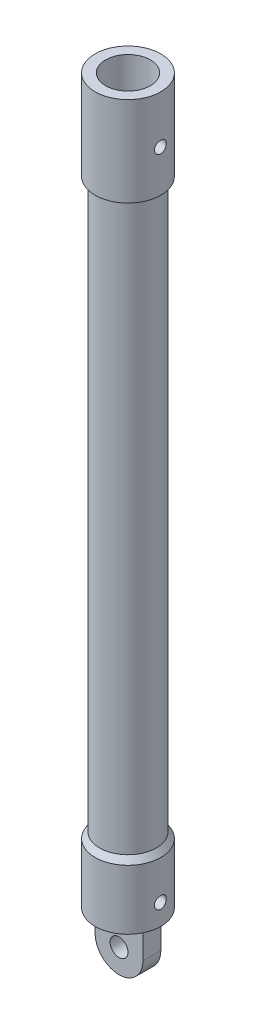
from build123d import *

# Parameters (mm, degrees)
BOSS_EXTRUDE1_DEPTH      = 1.5
BOSS_EXTRUDE1_DEPTH_BACK = 1.5
SKETCH2_R                = 1.5
SKETCH3_R                = 1
CUT_EXTRUDE1_DEPTH       = 10


with BuildPart() as part:
    # Sketch1 → Revolve1 (revolve)
    with BuildSketch(Plane.XY):
        Polygon((0, 0), (-5.5, 0), (-5.5, 10), (-4.75, 11), (-4.75, 106), (-5.5, 106), (-5.5, 121), (-3.75, 121), (-3.75, 2), (0, 2), align=None)
    revolve(axis=Axis((0, 121, 0), (0, -1, 0)))

    # Sketch2 → Boss-Extrude1 (add, two sides: drawn at the far end of the back side and taken through both)
    with BuildSketch(Plane.XY.offset(-BOSS_EXTRUDE1_DEPTH_BACK)):
        with BuildLine():
            Line((-4, 0), (4, 0))
            Line((4, 0), (4, -5))
            ThreePointArc((4, -5), (0, -9), (-4, -5))
            Line((-4, -5), (-4, 0))
        make_face()
        with Locations((0, -5)):
            Circle(SKETCH2_R, mode=Mode.SUBTRACT)
    extrude(amount=BOSS_EXTRUDE1_DEPTH + BOSS_EXTRUDE1_DEPTH_BACK)

    # Sketch3 → Cut-Extrude1 (cut)
    with BuildSketch(Plane(origin=(0, 0, 0), x_dir=(0, 0, -1), z_dir=(1, 0, 0))):
        with Locations((0, 3.5)):
            Circle(SKETCH3_R)
        with Locations((0, 113)):
            Circle(SKETCH3_R)
    extrude(amount=CUT_EXTRUDE1_DEPTH, mode=Mode.SUBTRACT)


solid = part.part
